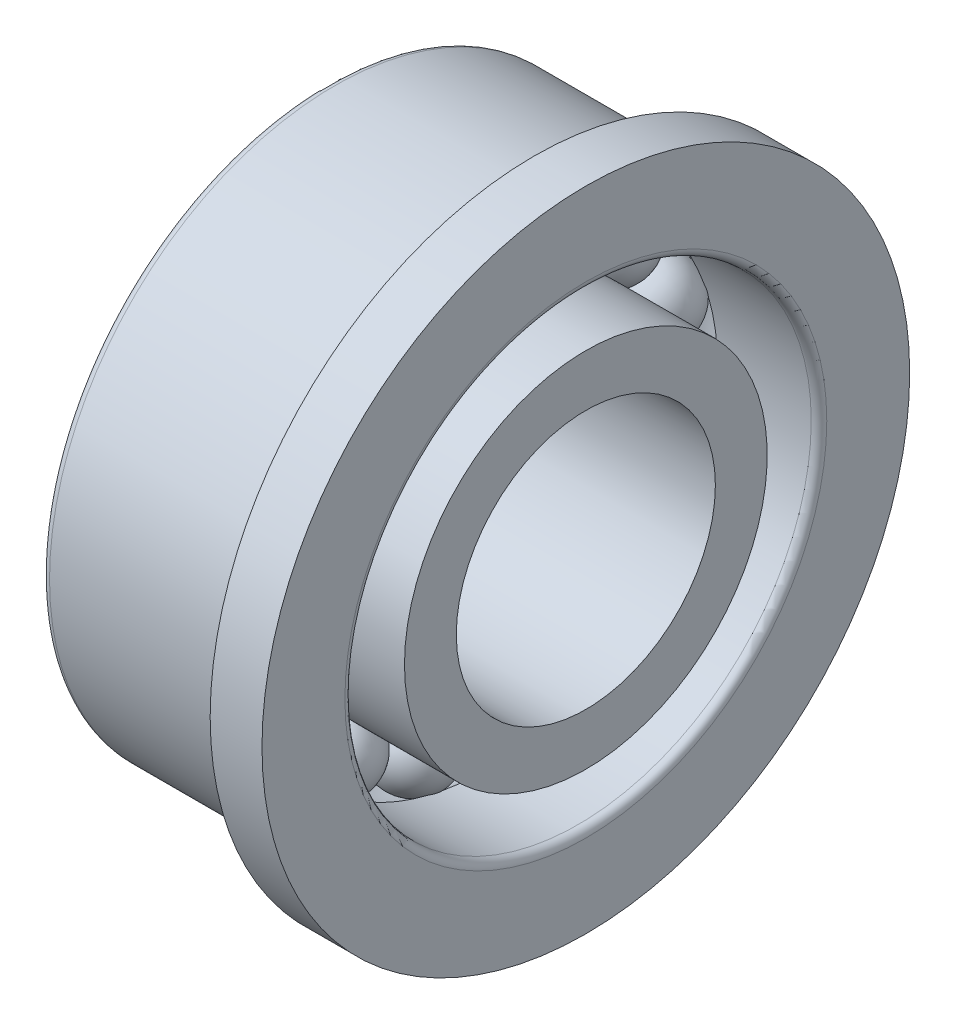
from build123d import *

# Parameters (mm, degrees)
CIRCULAR_PATTERN1_COUNT = 15
FILLET1_R               = 0.15


with BuildPart() as part:
    # Sketch1 → Revolve1 (revolve)
    with BuildSketch(Plane.XY):
        with BuildLine():
            Line((-0.75, 4), (0.75, 4))
            ThreePointArc((0.75, 4), (0, 3.25), (-0.75, 4))
        make_face()
    revolve1 = revolve(axis=Axis((-0.807148311, 4, 0), (1, 0, 0)))

    # Sketch2 → Revolve2 (revolve)
    with BuildSketch(Plane.XY, mode=Mode.PRIVATE) as revolve2_sk:
        with BuildLine():
            Line((-2.5, 3.5), (-0.545527268, 3.5))
            ThreePointArc((-0.545527268, 3.5), (0, 3.26), (0.545527268, 3.5))
            Line((0.545527268, 3.5), (2.5, 3.5))
            Line((2.5, 3.5), (2.5, 2.5))
            Line((2.5, 2.5), (-2.5, 2.5))
            Line((-2.5, 2.5), (-2.5, 3.5))
        make_face()
    revolve(revolve2_sk.sketch.rotate(Axis((-0.841709544, 0, 0), (1, 0, 0)), 90), axis=Axis((-0.841709544, 0, 0), (1, 0, 0)))

    # Sketch3 → Revolve3 (revolve)
    with BuildSketch(Plane.XY, mode=Mode.PRIVATE) as revolve3_sk:
        with BuildLine():
            Line((-2.5, 5.5), (-2.5, 4.5))
            Line((-2.5, 4.5), (-0.545527268, 4.5))
            ThreePointArc((-0.545527268, 4.5), (0, 4.74), (0.545527268, 4.5))
            Line((0.545527268, 4.5), (2.5, 4.5))
            Line((2.5, 4.5), (2.5, 6.25))
            Line((2.5, 6.25), (1.5, 6.25))
            Line((1.5, 6.25), (1.5, 5.5375))
            ThreePointArc((1.5, 5.5375), (1.526516504, 5.473483496), (1.4625, 5.5))
            Line((1.4625, 5.5), (-2.5, 5.5))
        make_face()
    revolve(revolve3_sk.sketch.rotate(Axis((-0.999715665, 0, 0), (1, 0, 0)), 90), axis=Axis((-0.999715665, 0, 0), (1, 0, 0)))

    # Circular-Pattern1: Revolve1 ×15 about axis
    circular_pattern1_axis = Axis((0, 0, 0), (1, 0, 0))
    for i in range(1, CIRCULAR_PATTERN1_COUNT):
        add(revolve1.rotate(circular_pattern1_axis, i * 360 / CIRCULAR_PATTERN1_COUNT))

    # Fillet1
    fillet1_edges = [part.edges().sort_by_distance(p)[0] for p in [
        (-2.5, 0, -5.5),
        (2.5, 0, -4.5),
        (-2.5, 0, -2.5),
    ]]
    fillet(fillet1_edges, radius=FILLET1_R)


solid = part.part
